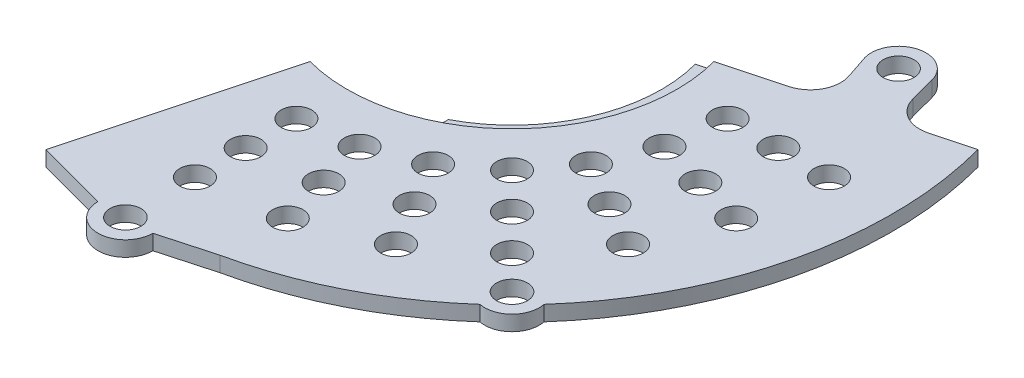
from build123d import *

# Parameters (mm, degrees)
BOSS_EXTRUDE2_DEPTH = 3
BOSS_EXTRUDE3_DEPTH = 1.5
SKETCH4_R           = 3
CUT_EXTRUDE1_DEPTH  = 10
CIRPATTERN2_COUNT   = 7
CIRPATTERN2_ANGLE   = 90
SKETCH7_R           = 3.047588699
BOSS_EXTRUDE5_DEPTH = 3
SKETCH7_3_R         = 3.047588699
CUT_EXTRUDE2_DEPTH  = 3
FILLET1_R           = 6


with BuildPart() as part:
    # Sketch2 → Boss-Extrude2 (new body)
    with BuildSketch(Plane(origin=(0, 0, 0), x_dir=(1, 0, 0), z_dir=(0, 1, 0))):
        with BuildLine():
            ThreePointArc((32.5, 0), (19.784746443, -25.783983559), (-8.411618966, -31.392589354))
            Line((-8.411618966, -31.392589354), (-19.411428383, -72.444436972))
            ThreePointArc((-19.411428383, -72.444436972), (45.657107176, -59.501500522), (75, 0))
            ThreePointArc((75, 0), (74.358364603, 9.789464417), (72.444436972, 19.411428383))
            Line((72.444436972, 19.411428383), (31.392589354, 8.411618966))
            ThreePointArc((31.392589354, 8.411618966), (32.221957995, 4.242101247), (32.5, 0))
        make_face()
    extrude(amount=BOSS_EXTRUDE2_DEPTH)

    # Sketch3 → Boss-Extrude3 (add)
    with BuildSketch(Plane.XZ):
        with BuildLine():
            ThreePointArc((8.411618966, 31.392589354), (0, 32.5), (-8.411618966, 31.392589354))
            Line((-8.411618966, 31.392589354), (8.411618966, 31.392589354))
        make_face()
        with BuildLine():
            Line((28.494811876, -7.635161831), (31.392589354, -8.411618966))
            ThreePointArc((31.392589354, -8.411618966), (32.221957995, -4.242101247), (32.5, 0))
            ThreePointArc((32.5, 0), (27.378025192, 17.512673599), (13.626539288, 29.505379629))
            Line((13.626539288, 29.505379629), (13.626539288, 26.16423947))
            ThreePointArc((13.626539288, 26.16423947), (25.221349181, 15.30142299), (29.5, 0))
            ThreePointArc((29.5, 0), (29.247623411, -3.85052267), (28.494811876, -7.635161831))
        make_face()
    extrude(amount=-BOSS_EXTRUDE3_DEPTH)

    # Sketch4 → Cut-Extrude1 (cut)
    with BuildSketch(Plane(origin=(0, 3, 0), x_dir=(1, 0, 0), z_dir=(0, 1, 0))):
        with Locations((0, -42.5)):
            Circle(SKETCH4_R)
        with Locations((0, -52.5)):
            Circle(SKETCH4_R)
        with Locations((0, -62.5)):
            Circle(SKETCH4_R)
    cut_extrude1 = extrude(amount=-CUT_EXTRUDE1_DEPTH, mode=Mode.SUBTRACT)

    # CirPattern2: Cut-Extrude1 ×7 about axis
    cirpattern2_axis = Axis((0, 0, 0), (0, 1, 0))
    for i in range(1, CIRPATTERN2_COUNT):
        add(cut_extrude1.rotate(cirpattern2_axis, i * CIRPATTERN2_ANGLE / (CIRPATTERN2_COUNT - 1)), mode=Mode.SUBTRACT)

    # Sketch7 → Boss-Extrude5 (add)
    with BuildSketch(Plane.XZ):
        with BuildLine():
            Line((-5.404581923, 76.2), (-19.411428383, 72.444436972))
            ThreePointArc((-19.411428383, 72.444436972), (-11.165518609, 74.164217748), (-2.77876912, 74.94850527))
            ThreePointArc((-2.77876912, 74.94850527), (0, 79.247588699), (2.77876912, 74.94850527))
            ThreePointArc((2.77876912, 74.94850527), (9.318606025, 74.41883889), (15.78712451, 73.319620155))
            Line((15.78712451, 73.319620155), (5.404581923, 76.2))
            ThreePointArc((5.404581923, 76.2), (0, 81.604581923), (-5.404581923, 76.2))
        make_face()
        with BuildLine():
            ThreePointArc((49.770964897, 56.105713196), (53.033008589, 53.033008589), (56.105713196, 49.770964897))
            ThreePointArc((56.105713196, 49.770964897), (54.621616527, 54.621616527), (49.770964897, 56.105713196))
        make_face()
        with BuildLine():
            Line((50.264676908, -9.974138925), (45.819583471, -23.301201068))
            ThreePointArc((45.819583471, -23.301201068), (49.037057403, -30.508966545), (56.0148967, -26.819280865))
            Line((56.0148967, -26.819280865), (58.942789983, -15.793672976))
            Line((58.942789983, -15.793672976), (58.942789983, -12.868627078))
            Line((58.942789983, -12.868627078), (50.264676908, -9.974138925))
        make_face()
        with Locations((50.8, -25.4)):
            Circle(SKETCH7_R, mode=Mode.SUBTRACT)
    extrude(amount=-BOSS_EXTRUDE5_DEPTH)

    # Sketch7_3 → Cut-Extrude2 (cut)
    with BuildSketch(Plane.XZ):
        with Locations((0, 76.2)):
            Circle(SKETCH7_3_R)
        with Locations((50.8, 50.8)):
            Circle(SKETCH7_3_R)
    extrude(amount=-CUT_EXTRUDE2_DEPTH, mode=Mode.SUBTRACT)

    # Fillet1
    fillet1_edges = [part.edges().sort_by_distance(p)[0] for p in [
        (49.194825936, 1.5, -13.181713881),
        (58.942789983, 1.5, -15.793672976),
    ]]
    fillet(fillet1_edges, radius=FILLET1_R)


solid = part.part
